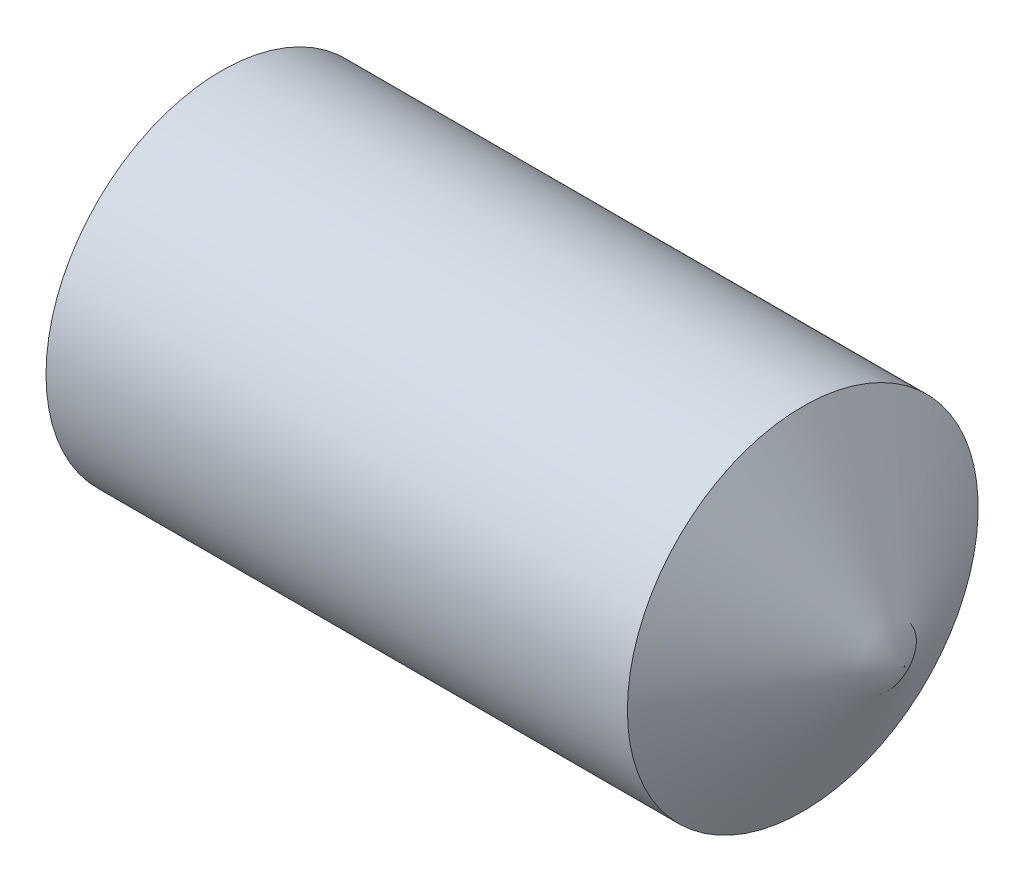
from build123d import *

# Parameters (mm, degrees)
HEX_2_DEPTH = 1.2


with BuildPart() as part:
    # BodySke → BaseBody (revolve)
    with BuildSketch(Plane.XY):
        Polygon((0, 0), (0, 1.2195), (0.161946751, 1.5), (5.133974596, 1.5), (6, 0), align=None)
    revolve(axis=Axis((-12.7, 0, 0), (1, 0, 0)))

    # Sketch2 → Hex 2 (cut)
    with BuildSketch(Plane.ZY):
        Polygon((0.433012702, 0.75), (-0.433012702, 0.75), (-0.866025404, 0), (-0.433012702, -0.75), (0.433012702, -0.75), (0.866025404, 0), align=None)
    extrude(amount=-HEX_2_DEPTH, mode=Mode.SUBTRACT)


solid = part.part
